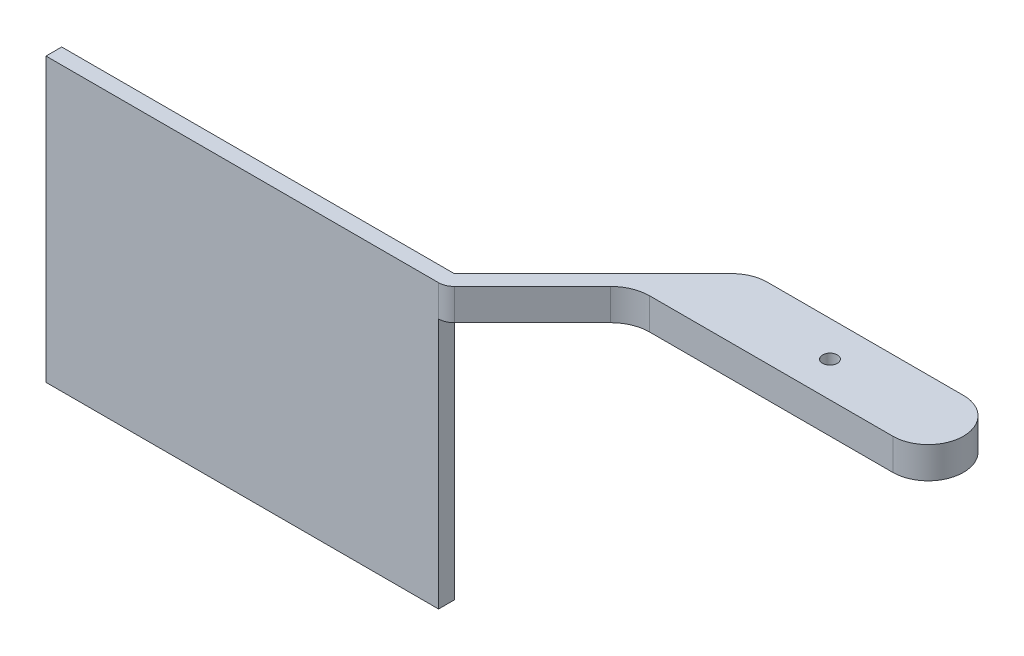
from build123d import *

# Parameters (mm, degrees)
RESSALTO_EXTRUS_O1_DEPTH = 4
ESBO_O2_W                = 50
ESBO_O2_H                = 2
RESSALTO_EXTRUS_O2_DEPTH = 32
ESBO_O3_R                = 0.94
CORTE_EXTRUS_O1_DEPTH    = 37
CORTE_EXTRUS_O2_DEPTH    = 2
FILETE1_R                = 2


with BuildPart() as part:
    # Esboço1 → Ressalto-extrusão1 (new body)
    with BuildSketch(Plane(origin=(0, 0, 0), x_dir=(1, 0, 0), z_dir=(0, 1, 0))):
        with BuildLine():
            Line((12.5, 4.5), (-12.5, 4.5))
            ThreePointArc((-12.5, 4.5), (-14.222075446, 4.157457896), (-15.681980515, 3.181980515))
            Line((-15.681980515, 3.181980515), (-33.359650045, -14.495689014))
            Line((-33.359650045, -14.495689014), (-83.359650045, -14.495689014))
            Line((-83.359650045, -14.495689014), (-83.359650045, -16.495689014))
            Line((-83.359650045, -16.495689014), (-32.53122292, -16.495689014))
            Line((-32.53122292, -16.495689014), (-22, -5.964466094))
            ThreePointArc((-22, -5.964466094), (-20.377883256, -4.880602337), (-18.464466094, -4.5))
            Line((-18.464466094, -4.5), (12.5, -4.5))
            ThreePointArc((12.5, -4.5), (17, 0), (12.5, 4.5))
        make_face()
    extrude(amount=-RESSALTO_EXTRUS_O1_DEPTH)

    # Esboço2 → Ressalto-extrusão2 (add)
    with BuildSketch(Plane.XZ.offset(4)):
        with Locations((-58.359650045, 15.495689014)):
            Rectangle(ESBO_O2_W, ESBO_O2_H)
    extrude(amount=RESSALTO_EXTRUS_O2_DEPTH)

    # Esboço3 → Corte-extrusão1 (cut, through all)
    with BuildSketch(Plane(origin=(0, 0, 0), x_dir=(1, 0, 0), z_dir=(0, 1, 0))):
        Circle(ESBO_O3_R)
    extrude(amount=-CORTE_EXTRUS_O1_DEPTH, mode=Mode.SUBTRACT)

    # Esboço6 → Corte-extrusão2 (cut)
    with BuildSketch(Plane(origin=(0, -4, 0), x_dir=(1, 0, 0), z_dir=(0, 1, 0))):
        with BuildLine():
            Line((-14.05, 2), (-2.209072203, 2.65))
            ThreePointArc((-2.209072203, 2.65), (0, 3.45), (2.209072203, 2.65))
            Line((2.209072203, 2.65), (14.05, 2))
            ThreePointArc((14.05, 2), (16.05, 0), (14.05, -2))
            Line((14.05, -2), (2.209072203, -2.65))
            ThreePointArc((2.209072203, -2.65), (0, -3.45), (-2.209072203, -2.65))
            Line((-2.209072203, -2.65), (-14.05, -2))
            ThreePointArc((-14.05, -2), (-16.05, 0), (-14.05, 2))
        make_face()
    extrude(amount=CORTE_EXTRUS_O2_DEPTH, mode=Mode.SUBTRACT)

    # Filete1
    filete1_edges = [part.edges().sort_by_distance(p)[0] for p in [
        (-32.53122292, -2, 16.495689014),
    ]]
    fillet(filete1_edges, radius=FILETE1_R)


solid = part.part
